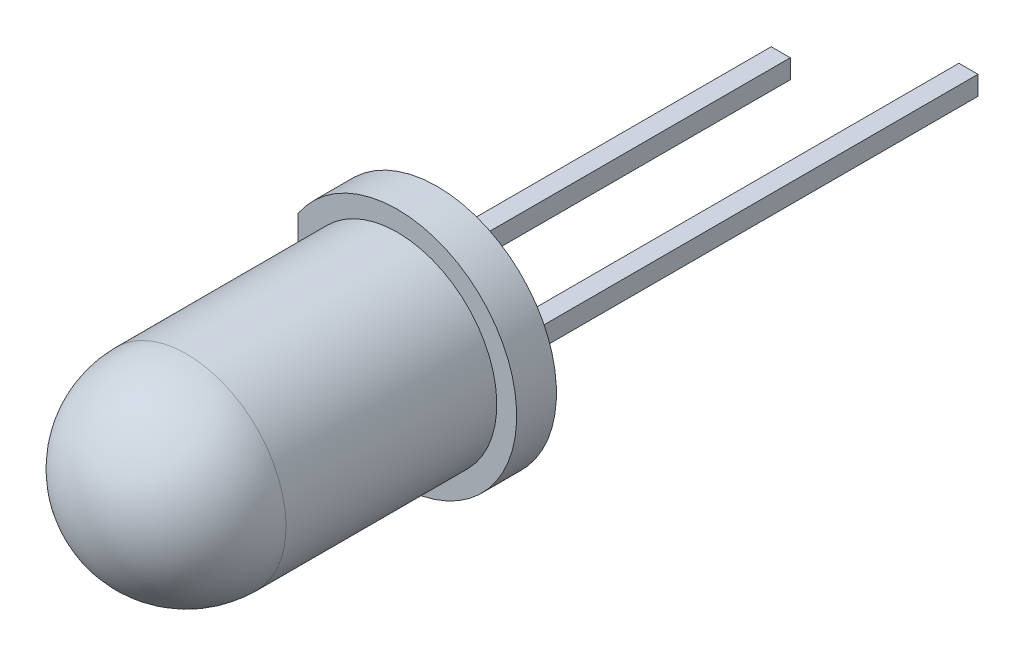
from build123d import *

# Parameters (mm, degrees)
ESBO_O1_R                  = 3
RESSALTO_EXTRUS_O1_DEPTH   = 1
CORTE_EXTRUS_O1_DEPTH      = 1
ESBO_O5_W                  = 0.48
ESBO_O5_H                  = 0.48
RESSALTO_EXTRUS_O2_DEPTH   = 10
RESSALTO_EXTRUS_O2_2_DEPTH = 10
ESBO_O6_W                  = 0.48
ESBO_O6_H                  = 0.48
RESSALTO_EXTRUS_O3_DEPTH   = 2
CORTE_EXTRUS_O2_DEPTH      = 0.24
RESSALTO_EXTRUS_O4_DEPTH   = 0.24
RESSALTO_EXTRUS_O4_2_DEPTH = 0.24
ESBO_O12_R                 = 0.2
CORTE_EXTRUS_O3_DEPTH      = 0.1


with BuildPart() as part:
    # Esbo_o1 → Ressalto-extrus_o1 (new body)
    with BuildSketch(Plane.XY):
        Circle(ESBO_O1_R)
    extrude(amount=RESSALTO_EXTRUS_O1_DEPTH)

    # Esbo_o3 → Revolu_o1 (revolve)
    with BuildSketch(Plane(origin=(0, 0, 0), x_dir=(0, 0, -1), z_dir=(1, 0, 0))):
        with BuildLine():
            Line((-1, 0), (-8.8, 0))
            ThreePointArc((-8.8, 0), (-8.067766953, 1.767766953), (-6.3, 2.5))
            Line((-6.3, 2.5), (-1, 2.5))
            Line((-1, 2.5), (-1, 0))
        make_face()
    revolve(axis=Axis((0, 0, 1), (0, 0, 1)))

    # Esbo_o4 → Corte-extrus_o1 (cut)
    with BuildSketch(Plane(origin=(0, 0, 0), x_dir=(-1, 0, 0), z_dir=(0, 0, -1))):
        with BuildLine():
            Line((2.5, 1.658312395), (2.5, -1.658312395))
            ThreePointArc((2.5, -1.658312395), (3, 0), (2.5, 1.658312395))
        make_face()
    extrude(amount=-CORTE_EXTRUS_O1_DEPTH, mode=Mode.SUBTRACT)

    # Esbo_o7 → Corte-extrus_o2 (cut, symmetric)
    with BuildSketch(Plane(origin=(0, 0, 0), x_dir=(1, 0, 0), z_dir=(0, 1, 0))):
        Polygon((-1.6, 0), (-1.6, -3.5), (-1.3, -4), (1.2, -4), (0.02, -2), (-1.12, -2), (-1.12, 0), align=None)
        Polygon((1.6, 0), (1.6, -4), (1.4, -4), (0.22, -2), (1.12, -2), (1.12, 0), align=None)
    extrude(amount=CORTE_EXTRUS_O2_DEPTH, both=True, mode=Mode.SUBTRACT)


with BuildPart() as body_2:
    # Esbo_o5 → Ressalto-extrus_o2 (new body)
    with BuildSketch(Plane(origin=(0, 0, 0), x_dir=(-1, 0, 0), z_dir=(0, 0, -1))):
        with Locations((-1.36, 0)):
            Rectangle(ESBO_O5_W, ESBO_O5_H)
    extrude(amount=RESSALTO_EXTRUS_O2_DEPTH)


with BuildPart() as body_3:
    # Esbo_o5 → Ressalto-extrus_o2 2 (new body)
    with BuildSketch(Plane(origin=(0, 0, 0), x_dir=(-1, 0, 0), z_dir=(0, 0, -1))):
        with Locations((1.36, 0)):
            Rectangle(ESBO_O5_W, ESBO_O5_H)
    extrude(amount=RESSALTO_EXTRUS_O2_2_DEPTH)


with BuildPart() as body_4:
    # Esbo_o6 → Ressalto-extrus_o3 (new body)
    with BuildSketch(Plane(origin=(0, 0, -10), x_dir=(-1, 0, 0), z_dir=(0, 0, -1))):
        with Locations((-1.36, 0)):
            Rectangle(ESBO_O6_W, ESBO_O6_H)
    extrude(amount=RESSALTO_EXTRUS_O3_DEPTH)


with BuildPart() as body_5:
    # Esbo_o8 → Ressalto-extrus_o4 (new body, symmetric)
    with BuildSketch(Plane(origin=(0, 0, 0), x_dir=(1, 0, 0), z_dir=(0, 1, 0))):
        Polygon((-1.3, -4), (1.2, -4), (0.02, -2), (-1.12, -2), (-1.12, 0), (-1.6, 0), (-1.6, -3.5), align=None)
    extrude(amount=RESSALTO_EXTRUS_O4_DEPTH, both=True)

    # Combinar2: union body 3
    add(body_3.part)

    # Esbo_o10 → Corte-Revolu_o1 (revolve, cut)
    with BuildSketch(Plane(origin=(0, 0, 0), x_dir=(1, 0, 0), z_dir=(0, 1, 0))):
        with BuildLine():
            Line((-0.05, -4), (-0.05, -3.7))
            ThreePointArc((-0.05, -3.7), (-0.341547595, -3.780754009), (-0.55, -4))
            Line((-0.55, -4), (-0.05, -4))
        make_face()
    revolve(axis=Axis((-0.05, 0, 4), (0, 0, -1)), mode=Mode.SUBTRACT)


with BuildPart() as body_6:
    # Esbo_o8 → Ressalto-extrus_o4 2 (new body, symmetric)
    with BuildSketch(Plane(origin=(0, 0, 0), x_dir=(1, 0, 0), z_dir=(0, 1, 0))):
        Polygon((0.22, -2), (1.4, -4), (1.6, -4), (1.6, 0), (1.12, 0), (1.12, -2), align=None)
    extrude(amount=RESSALTO_EXTRUS_O4_2_DEPTH, both=True)

    # Combinar1: union body 4, body 2
    add(body_4.part)
    add(body_2.part)


with BuildPart() as body_4_2:
    # Esbo_o11 → Revolu_o2 (revolve)
    with BuildSketch(Plane(origin=(0, 0, 0), x_dir=(1, 0, 0), z_dir=(0, 1, 0))):
        with BuildLine():
            Line((-0.55, -4), (-0.05, -4))
            Line((-0.05, -4), (-0.05, -3.7))
            ThreePointArc((-0.05, -3.7), (-0.341547595, -3.780754009), (-0.55, -4))
        make_face()
    revolve(axis=Axis((-0.05, 0, 4), (0, 0, -1)))

    # Combinar3: union body 5
    add(body_5.part)

    # Esbo_o12 → Corte-extrus_o3 (cut)
    with BuildSketch(Plane.XY.offset(4)):
        with Locations((-0.05, 0)):
            Circle(ESBO_O12_R)
    extrude(amount=-CORTE_EXTRUS_O3_DEPTH, mode=Mode.SUBTRACT)


solid = Compound([part.part, body_6.part, body_4_2.part])
